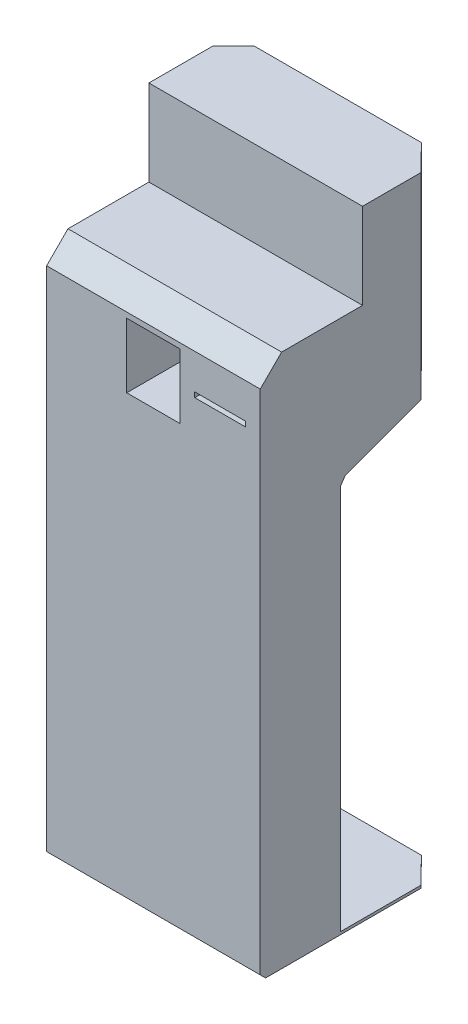
from build123d import *

# Parameters (mm, degrees)
BOSS_EXTRUDE1_DEPTH     = 400
SKETCH2_W               = 100
SKETCH2_H               = 121
SKETCH2_W_2             = 95.3
SKETCH2_H_2             = 9.4
CUT_EXTRUDE1_DEPTH      = 268
CUT_EXTRUDE2_DEPTH      = 1
CUT_EXTRUDE2_DEPTH_BACK = 1161.696902422


with BuildPart() as part:
    # Sketch1 → Boss-Extrude1 (new body)
    with BuildSketch(Plane(origin=(0, 0, 0), x_dir=(0, 0, -1), z_dir=(1, 0, 0))):
        Polygon((0, 0), (-340, 0), (-350, 10), (-350, 960), (-310, 1000), (-158.48888922, 1000), (-158.48888922, 1160.696902422), (-108.48888922, 1160.696902422), (0, 1160.696902422), (0, 1000), (0, 970), (0, 820), (-9.396926208, 806.579798567), (-27.474774195, 800), (-190.603073792, 740.62615458), (-200, 727.205953147), (-200, 5), (0, 5), align=None)
    extrude(amount=BOSS_EXTRUDE1_DEPTH)

    # Sketch2 → Cut-Extrude1 (cut)
    with BuildSketch(Plane.XY.offset(350)):
        with Locations((200, 889.5)):
            Rectangle(SKETCH2_W, SKETCH2_H)
        with Locations((325, 889.5)):
            Rectangle(SKETCH2_W_2, SKETCH2_H_2)
    extrude(amount=-CUT_EXTRUDE1_DEPTH, mode=Mode.SUBTRACT)

    # Sketch3 → Cut-Extrude2 (cut, two sides)
    with BuildSketch(Plane(origin=(0, 0, 0), x_dir=(-1, 0, 0), z_dir=(0, -1, 0))) as cut_extrude2_sk:
        Polygon((32.971910004, -72.804395349), (-67.728153305, 29.569560354), (-322.648629759, 29.569560354), (-423.348693067, -72.804395349), (-423.348693067, 100.069531779), (32.971910004, 100.069531779), align=None)
    extrude(amount=CUT_EXTRUDE2_DEPTH, mode=Mode.SUBTRACT)
    extrude(cut_extrude2_sk.sketch, amount=-CUT_EXTRUDE2_DEPTH_BACK, mode=Mode.SUBTRACT)


solid = part.part
